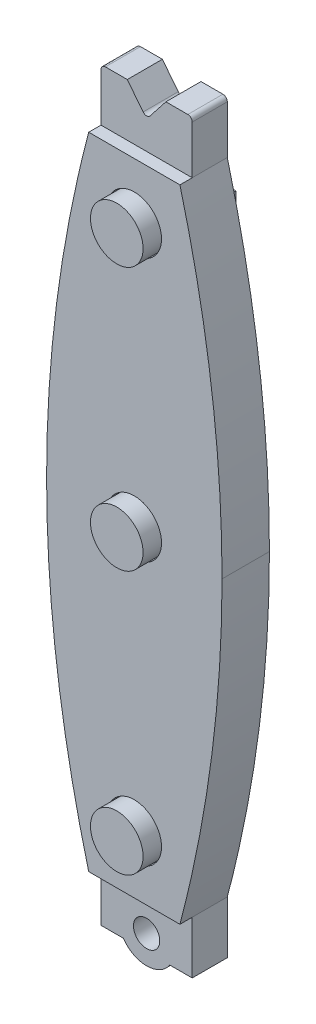
from build123d import *

# Parameters (mm, degrees)
SKETCH1_W           = 25.4
SKETCH1_H           = 92.71
BOSS_EXTRUDE1_DEPTH = 5.08
SKETCH3_W           = 13.208
SKETCH3_H           = 5.08
BOSS_EXTRUDE3_DEPTH = 11.938
SKETCH5_R           = 1.905
CUT_EXTRUDE2_DEPTH  = 6.08
SKETCH7_W           = 25.4
SKETCH7_H           = 92.71
BOSS_EXTRUDE4_DEPTH = 1.778
SKETCH8_R           = 3.937
CUT_EXTRUDE3_DEPTH  = 1.27
SKETCH10_R          = 3.81
BOSS_EXTRUDE5_DEPTH = 3.81
SKETCH11_W          = 13.208
SKETCH11_H          = 5.08
BOSS_EXTRUDE6_DEPTH = 7.62
CUT_EXTRUDE4_DEPTH  = 6.08
FILLET1_R           = 0.635
CUT_EXTRUDE7_DEPTH  = 7.62
CUT_EXTRUDE8_DEPTH  = 7.8580001
SKETCH17_W          = 12.7
SKETCH17_H          = 82.55
BOSS_EXTRUDE7_DEPTH = 1.524


with BuildPart() as part:
    # Sketch1 → Boss-Extrude1 (new body)
    with BuildSketch(Plane.XY):
        with Locations((-20.361983471, -4.405640496)):
            Rectangle(SKETCH1_W, SKETCH1_H)
    extrude(amount=BOSS_EXTRUDE1_DEPTH)

    # Sketch3 → Boss-Extrude3 (add)
    with BuildSketch(Plane.XZ.offset(50.760640496)):
        with Locations((-20.361983471, 2.54)):
            Rectangle(SKETCH3_W, SKETCH3_H)
    extrude(amount=BOSS_EXTRUDE3_DEPTH)

    # Sketch5 → Cut-Extrude2 (cut, through all)
    with BuildSketch(Plane.XY.offset(5.08)):
        with Locations((-20.361983471, -56.094640496)):
            Circle(SKETCH5_R)
        with BuildLine():
            Line((-23.722087636, -58.380640496), (-26.965983471, -58.380640496))
            Line((-26.965983471, -58.380640496), (-26.965983471, -62.698640496))
            Line((-26.965983471, -62.698640496), (-13.757983471, -62.698640496))
            Line((-13.757983471, -62.698640496), (-13.757983471, -58.380640496))
            Line((-13.757983471, -58.380640496), (-17.001879306, -58.380640496))
            ThreePointArc((-17.001879306, -58.380640496), (-20.361983471, -60.158640496), (-23.722087636, -58.380640496))
        make_face()
    extrude(amount=-CUT_EXTRUDE2_DEPTH, mode=Mode.SUBTRACT)

    # Sketch7 → Boss-Extrude4 (add)
    with BuildSketch(Plane.XY.offset(5.08)):
        with Locations((-20.361983471, -4.405640496)):
            Rectangle(SKETCH7_W, SKETCH7_H)
    extrude(amount=BOSS_EXTRUDE4_DEPTH)

    # Sketch8 → Cut-Extrude3 (cut)
    with BuildSketch(Plane.XY.offset(6.858)):
        with Locations((-20.361983471, -42.378640496)):
            Circle(SKETCH8_R)
        with Locations((-20.361983471, -4.278640496)):
            Circle(SKETCH8_R)
        with Locations((-20.361983471, 33.821359504)):
            Circle(SKETCH8_R)
    extrude(amount=-CUT_EXTRUDE3_DEPTH, mode=Mode.SUBTRACT)

    # Sketch10 → Boss-Extrude5 (add)
    with BuildSketch(Plane.XY.offset(5.588)):
        with Locations((-20.361983471, -42.378640496)):
            Circle(SKETCH10_R)
        with Locations((-20.361983471, -4.278640496)):
            Circle(SKETCH10_R)
        with Locations((-20.361983471, 33.821359504)):
            Circle(SKETCH10_R)
    extrude(amount=BOSS_EXTRUDE5_DEPTH)

    # Sketch11 → Boss-Extrude6 (add)
    with BuildSketch(Plane(origin=(0, 41.949359504, 0), x_dir=(1, 0, 0), z_dir=(0, 1, 0))):
        with Locations((-20.361983471, -2.54)):
            Rectangle(SKETCH11_W, SKETCH11_H)
    extrude(amount=BOSS_EXTRUDE6_DEPTH)

    # Sketch12 → Cut-Extrude4 (cut, through all)
    with BuildSketch(Plane.XY.offset(5.08)):
        Polygon((-23.155983471, 49.569359504), (-20.361983471, 46.013359504), (-17.567983471, 49.569359504), align=None)
    extrude(amount=-CUT_EXTRUDE4_DEPTH, mode=Mode.SUBTRACT)

    # Fillet1
    fillet1_edges = [part.edges().sort_by_distance(p)[0] for p in [
        (-20.361983471, 46.013359504, 2.54),
        (-26.965983471, 49.569359504, 2.54),
        (-13.757983471, 49.569359504, 2.54),
    ]]
    fillet(fillet1_edges, radius=FILLET1_R)

    # Sketch14 → Cut-Extrude7 (cut)
    with BuildSketch(Plane.XY.offset(6.858)):
        with BuildLine():
            Line((-13.757983471, 41.949359504), (-7.661983471, 41.949359504))
            Line((-7.661983471, 41.949359504), (-7.661983471, -4.405640496))
            add(Edge.make_bspline(
                [(-13.757983471, 41.949359504), (-7.661983471, 18.771859504), (-7.661983471, -4.405640496)],
                knots=[0, 0, 0, 0.5, 0.5, 0.5], degree=2))
        make_face()
        with BuildLine():
            Line((-33.061983471, -4.405640496), (-33.061983471, 41.949359504))
            Line((-33.061983471, 41.949359504), (-26.965983471, 41.949359504))
            add(Edge.make_bspline(
                [(-26.965983471, 41.949359504), (-33.061983471, 18.771859504), (-33.061983471, -4.405640496)],
                knots=[0, 0, 0, 0.5, 0.5, 0.5], degree=2))
        make_face()
    extrude(amount=-CUT_EXTRUDE7_DEPTH, mode=Mode.SUBTRACT)

    # Sketch16 → Cut-Extrude8 (cut, through all)
    with BuildSketch(Plane.XY.offset(6.858)):
        with BuildLine():
            Line((-33.061983471, -4.405640496), (-33.061983471, -50.760640496))
            Line((-33.061983471, -50.760640496), (-26.965983471, -50.760640496))
            add(Edge.make_bspline(
                [(-33.061983471, -4.405640496), (-33.061983471, -27.583140496), (-26.965983471, -50.760640496)],
                knots=[0.5, 0.5, 0.5, 1, 1, 1], degree=2))
        make_face()
        with BuildLine():
            Line((-7.661983471, -4.405640496), (-7.661983471, -50.760640496))
            Line((-7.661983471, -50.760640496), (-13.757983471, -50.760640496))
            add(Edge.make_bspline(
                [(-13.757983471, -50.760640496), (-7.661983471, -27.583140496), (-7.661983471, -4.405640496)],
                knots=[0, 0, 0, 0.5, 0.5, 0.5], degree=2))
        make_face()
    extrude(amount=-CUT_EXTRUDE8_DEPTH, mode=Mode.SUBTRACT)

    # Sketch17 → Boss-Extrude7 (add)
    with BuildSketch(Plane(origin=(0, 0, 0), x_dir=(-1, 0, 0), z_dir=(0, 0, -1))):
        with Locations((20.361983471, -4.405640496)):
            Rectangle(SKETCH17_W, SKETCH17_H)
    extrude(amount=BOSS_EXTRUDE7_DEPTH)


solid = part.part
